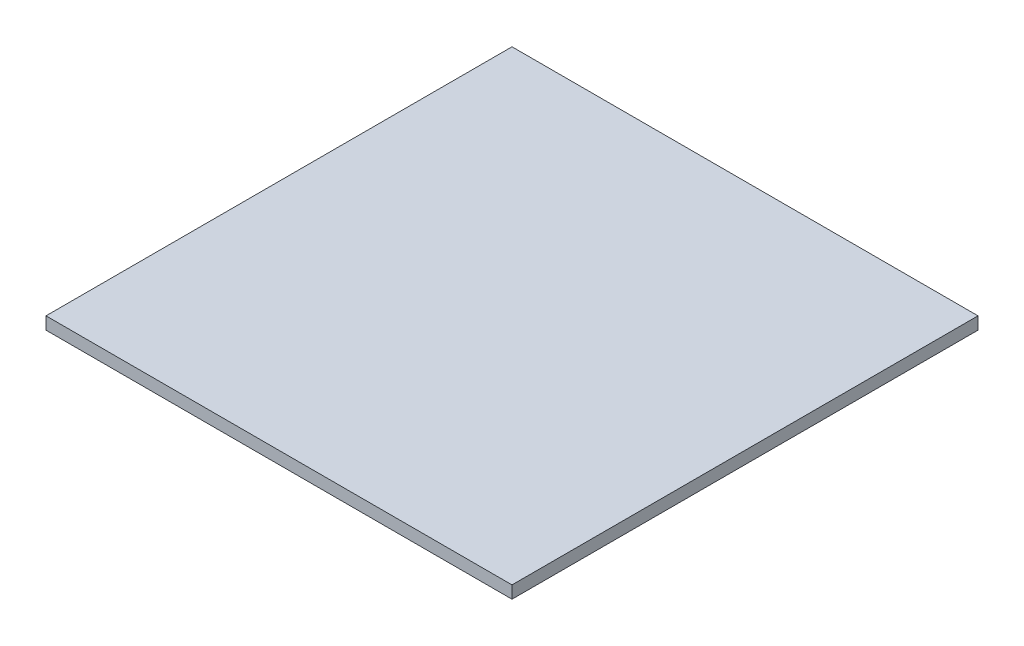
from build123d import *

# Parameters (mm, degrees)
SKETCH1_W           = 150
SKETCH1_H           = 150
BOSS_EXTRUDE1_DEPTH = 4


with BuildPart() as part:
    # Sketch1 → Boss-Extrude1 (new body)
    with BuildSketch(Plane(origin=(0, 0, 0), x_dir=(1, 0, 0), z_dir=(0, 1, 0))):
        with Locations((75, 75)):
            Rectangle(SKETCH1_W, SKETCH1_H)
    extrude(amount=BOSS_EXTRUDE1_DEPTH)


solid = part.part
